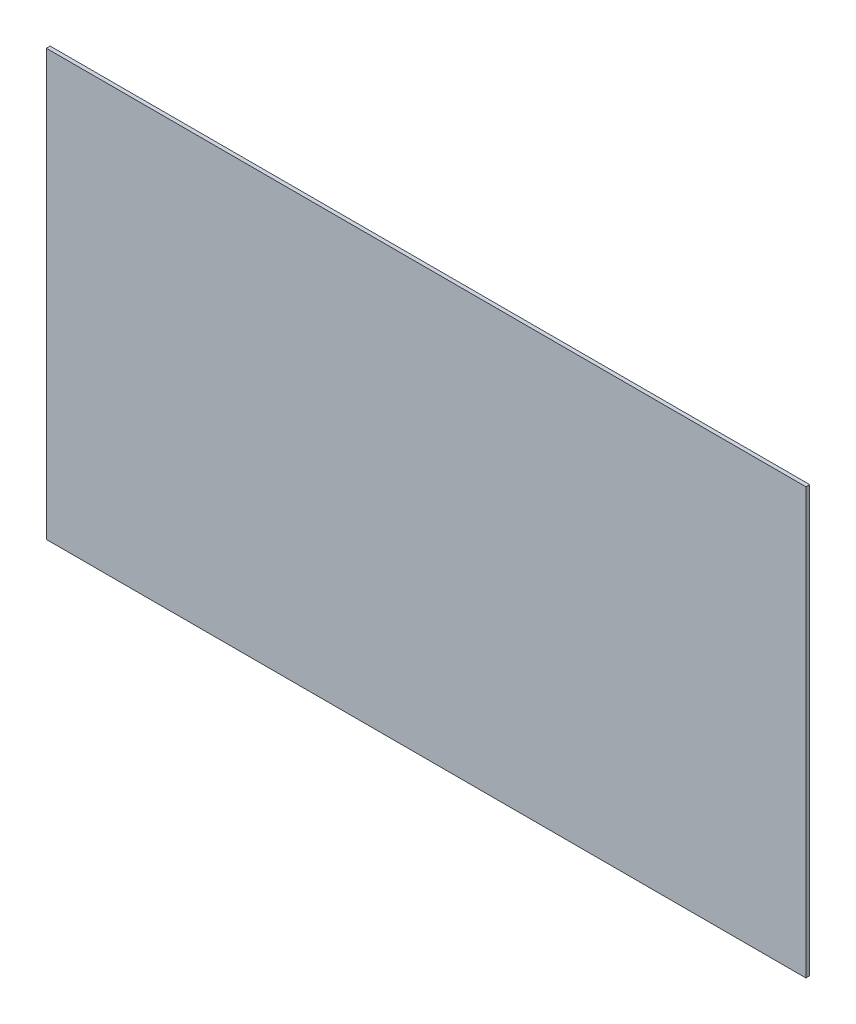
from build123d import *

# Parameters (mm, degrees)
IZIM1_W                     = 600
IZIM1_H                     = 336
Y_KSEKLIK_EKSTR_ZYON1_DEPTH = 3


with BuildPart() as part:
    # Çizim1 → Yükseklik-Ekstrüzyon1 (new body)
    with BuildSketch(Plane.XY):
        with Locations((300, -168)):
            Rectangle(IZIM1_W, IZIM1_H)
    extrude(amount=Y_KSEKLIK_EKSTR_ZYON1_DEPTH)


solid = part.part
